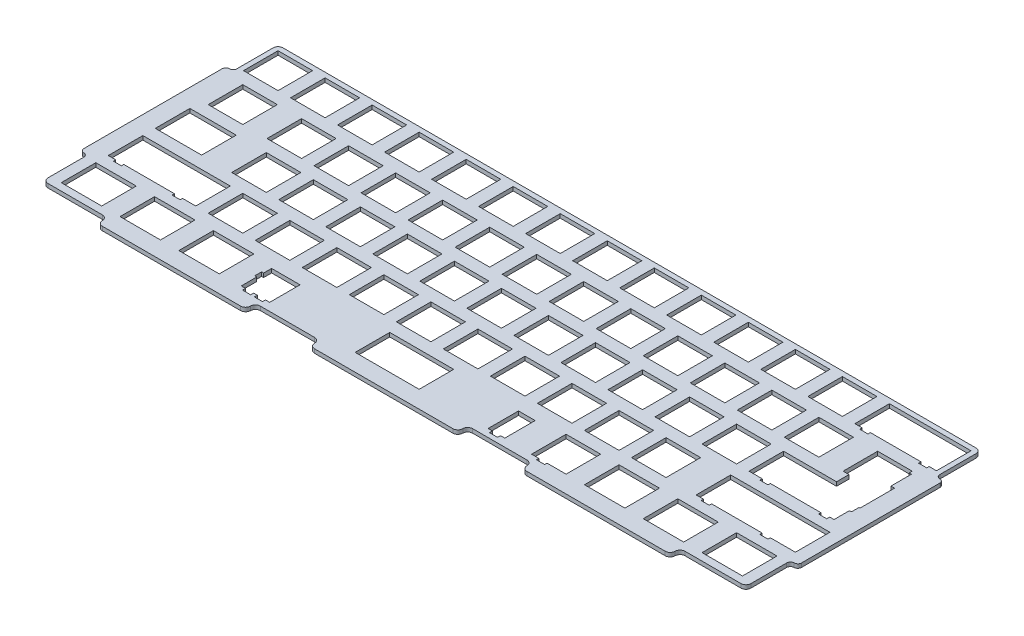
from build123d import *

# Parameters (mm, degrees)
SKETCH1_W           = 16.381
SKETCH1_H           = 13.99946
SKETCH1_W_2         = 16.38
SKETCH1_W_3         = 16.3805
SKETCH1_W_4         = 16.382
SKETCH1_W_5         = 16.38079
SKETCH1_W_6         = 14
SKETCH1_H_2         = 13.9994
SKETCH1_W_7         = 13.9993
SKETCH1_H_3         = 13.9993
SKETCH1_W_8         = 13.9998
SKETCH1_W_9         = 18.76199
SKETCH1_W_10        = 13.999
SKETCH1_W_11        = 13.99954
SKETCH1_W_12        = 14.001
SKETCH1_W_13        = 14.0007
SKETCH1_W_14        = 13.99955
BOSS_EXTRUDE2_DEPTH = 1.6


with BuildPart() as part:
    # Sketch1 → Boss-Extrude2 (new body)
    with BuildSketch(Plane(origin=(0, 0, 0), x_dir=(1, 0, 0), z_dir=(0, 1, 0))):
        with BuildLine():
            Line((-113.173608787, -49.920818918), (-57.173608787, -49.920818918))
            ThreePointArc((-57.173608787, -49.920818918), (-55.759395225, -49.33503248), (-55.173608787, -47.920818918))
            ThreePointArc((-55.173608787, -47.920818918), (-54.58782235, -46.506605356), (-53.173608787, -45.920818918))
            Line((-53.173608787, -45.920818918), (-31.173608787, -45.920818918))
            ThreePointArc((-31.173608787, -45.920818918), (-29.759395225, -46.506605356), (-29.173608787, -47.920818918))
            ThreePointArc((-29.173608787, -47.920818918), (-28.58782235, -49.33503248), (-27.173608787, -49.920818918))
            Line((-27.173608787, -49.920818918), (28.826391213, -49.920818918))
            ThreePointArc((28.826391213, -49.920818918), (30.240604775, -49.33503248), (30.826391213, -47.920818918))
            ThreePointArc((30.826391213, -47.920818918), (31.41217765, -46.506605356), (32.826391213, -45.920818918))
            Line((32.826391213, -45.920818918), (54.826391213, -45.920818918))
            ThreePointArc((54.826391213, -45.920818918), (56.240604775, -46.506605356), (56.826391213, -47.920818918))
            ThreePointArc((56.826391213, -47.920818918), (57.41217765, -49.33503248), (58.826391213, -49.920818918))
            Line((58.826391213, -49.920818918), (114.826391213, -49.920818918))
            ThreePointArc((114.826391213, -49.920818918), (116.240604775, -49.33503248), (116.826391213, -47.920818918))
            ThreePointArc((116.826391213, -47.920818918), (117.41217765, -46.506605356), (118.826391213, -45.920818918))
            Line((118.826391213, -45.920818918), (141.525741213, -45.920818918))
            ThreePointArc((141.525741213, -45.920818918), (142.939954775, -45.33503248), (143.525741213, -43.920818918))
            Line((143.525741213, -43.920818918), (143.525741213, -29.420818918))
            ThreePointArc((143.525741213, -29.420818918), (143.965081041, -28.360158746), (145.025741213, -27.920818918))
            ThreePointArc((145.025741213, -27.920818918), (146.086401385, -27.48147909), (146.525741213, -26.420818918))
            Line((146.525741213, -26.420818918), (146.525741213, 29.579181082))
            ThreePointArc((146.525741213, 29.579181082), (146.086401385, 30.639841254), (145.025741213, 31.079181082))
            ThreePointArc((145.025741213, 31.079181082), (143.965081041, 31.51852091), (143.525741213, 32.579181082))
            Line((143.525741213, 32.579181082), (143.525741213, 47.248781082))
            ThreePointArc((143.525741213, 47.248781082), (142.939954775, 48.662994644), (141.525741213, 49.248781082))
            Line((141.525741213, 49.248781082), (-139.173608787, 49.248781082))
            ThreePointArc((-139.173608787, 49.248781082), (-140.58782235, 48.662994644), (-141.173608787, 47.248781082))
            Line((-141.173608787, 47.248781082), (-141.173608787, 32.579181082))
            ThreePointArc((-141.173608787, 32.579181082), (-141.612948615, 31.51852091), (-142.673608787, 31.079181082))
            ThreePointArc((-142.673608787, 31.079181082), (-143.734268959, 30.639841254), (-144.173608787, 29.579181082))
            Line((-144.173608787, 29.579181082), (-144.173608787, -26.420818918))
            ThreePointArc((-144.173608787, -26.420818918), (-143.734268959, -27.48147909), (-142.673608787, -27.920818918))
            ThreePointArc((-142.673608787, -27.920818918), (-141.612948615, -28.360158746), (-141.173608787, -29.420818918))
            Line((-141.173608787, -29.420818918), (-141.173608787, -43.920818918))
            ThreePointArc((-141.173608787, -43.920818918), (-140.58782235, -45.33503248), (-139.173608787, -45.920818918))
            Line((-139.173608787, -45.920818918), (-117.173608787, -45.920818918))
            ThreePointArc((-117.173608787, -45.920818918), (-115.759395225, -46.506605356), (-115.173608787, -47.920818918))
            ThreePointArc((-115.173608787, -47.920818918), (-114.58782235, -49.33503248), (-113.173608787, -49.920818918))
        make_face()
        Polygon((-17.731258787, -28.951218918), (-17.731258787, -33.651718918), (-17.731258787, -42.950678918), (8.175741213, -42.950678918), (8.175741213, -38.251588918), (8.175741213, -33.651718918), (8.175741213, -28.951218918), align=None, mode=Mode.SUBTRACT)
        Polygon((-52.598358787, -33.651718918), (-52.598358787, -30.421518918), (-64.106258787, -30.421518918), (-64.106258787, -33.651718918), (-64.930358787, -33.651718918), (-64.930358787, -36.450478918), (-64.106258787, -36.450478918), (-64.106258787, -42.720548918), (-62.381258787, -42.720548918), (-62.381258787, -43.920818918), (-59.080658787, -43.920818918), (-59.080658787, -42.720548918), (-57.624058787, -42.720548918), (-57.624058787, -43.920818918), (-54.323758787, -43.920818918), (-54.323758787, -42.720548918), (-52.598358787, -42.720548918), (-52.598358787, -38.251588918), align=None, mode=Mode.SUBTRACT)
        Polygon((35.893741213, -33.651718918), (35.893741213, -42.720548918), (37.618741213, -42.720548918), (37.618741213, -43.920818918), (40.919741213, -43.920818918), (40.919741213, -42.720548918), (42.644741213, -42.720548918), (42.644741213, -38.251588918), (42.644741213, -33.651718918), (42.644741213, -30.421518918), (35.893741213, -30.421518918), align=None, mode=Mode.SUBTRACT)
        Polygon((53.707741213, -38.251588918), (53.707741213, -42.950678918), (56.675741213, -42.950678918), (56.675741213, -43.920818918), (59.975741213, -43.920818918), (59.975741213, -42.950678918), (67.706741213, -42.950678918), (67.706741213, -28.951218918), (53.707741213, -28.951218918), (53.707741213, -33.651718918), align=None, mode=Mode.SUBTRACT)
        with Locations((130.954241213, -35.950948918)):
            Rectangle(SKETCH1_W, SKETCH1_H, mode=Mode.SUBTRACT)
        with Locations((107.141741213, -35.950948918)):
            Rectangle(SKETCH1_W_2, SKETCH1_H, mode=Mode.SUBTRACT)
        with Locations((83.329241213, -35.950948918)):
            Rectangle(SKETCH1_W, SKETCH1_H, mode=Mode.SUBTRACT)
        with Locations((-80.977008787, -35.950948918)):
            Rectangle(SKETCH1_W_3, SKETCH1_H, mode=Mode.SUBTRACT)
        with Locations((-104.790258787, -35.950948918)):
            Rectangle(SKETCH1_W_4, SKETCH1_H, mode=Mode.SUBTRACT)
        with Locations((-128.601953787, -35.950948918)):
            Rectangle(SKETCH1_W_5, SKETCH1_H, mode=Mode.SUBTRACT)
        Polygon((101.332741213, -9.901318918), (101.332741213, -23.900718918), (104.307741213, -23.900718918), (104.307741213, -24.870818918), (107.606741213, -24.870818918), (107.606741213, -23.900718918), (124.856741213, -23.900718918), (127.526741213, -23.900718918), (128.106741213, -23.900718918), (128.106741213, -24.870818918), (131.406741213, -24.870818918), (131.406741213, -23.900718918), (141.525741213, -23.900718918), (141.525741213, -9.901318918), (127.526741213, -9.901318918), (124.856741213, -9.901318918), align=None, mode=Mode.SUBTRACT)
        Polygon((-136.792348787, -9.901318918), (-136.792348787, -23.900718918), (-133.817168787, -23.900718918), (-133.817168787, -24.870818918), (-130.518158787, -24.870818918), (-130.518158787, -23.900718918), (-110.018458787, -23.900718918), (-110.018458787, -24.870818918), (-106.718058787, -24.870818918), (-106.718058787, -23.900718918), (-101.361758787, -23.900718918), (-101.361758787, -9.901318918), align=None, mode=Mode.SUBTRACT)
        with Locations((82.138741213, -16.901018918)):
            Rectangle(SKETCH1_W_6, SKETCH1_H_2, mode=Mode.SUBTRACT)
        with Locations((63.088741213, -16.901018918)):
            Rectangle(SKETCH1_W_6, SKETCH1_H_2, mode=Mode.SUBTRACT)
        with Locations((44.038741213, -16.901018918)):
            Rectangle(SKETCH1_W_6, SKETCH1_H_2, mode=Mode.SUBTRACT)
        with Locations((24.988741213, -16.901018918)):
            Rectangle(SKETCH1_W_6, SKETCH1_H_2, mode=Mode.SUBTRACT)
        with Locations((5.938741213, -16.901018918)):
            Rectangle(SKETCH1_W_6, SKETCH1_H_2, mode=Mode.SUBTRACT)
        with Locations((-13.111258787, -16.901018918)):
            Rectangle(SKETCH1_W_6, SKETCH1_H_2, mode=Mode.SUBTRACT)
        with Locations((-32.161258787, -16.901018918)):
            Rectangle(SKETCH1_W_6, SKETCH1_H_2, mode=Mode.SUBTRACT)
        with Locations((-51.211408787, -16.901018918)):
            Rectangle(SKETCH1_W_7, SKETCH1_H_2, mode=Mode.SUBTRACT)
        with Locations((-70.261408787, -16.901018918)):
            Rectangle(SKETCH1_W_7, SKETCH1_H_2, mode=Mode.SUBTRACT)
        with Locations((-89.311408787, -16.901018918)):
            Rectangle(SKETCH1_W_7, SKETCH1_H_2, mode=Mode.SUBTRACT)
        Polygon((122.763741213, 28.198781082), (122.763741213, 14.199481082), (125.143741213, 14.199481082), (125.143741213, 9.148781082), (103.713741213, 9.148781082), (103.713741213, -4.850518918), (109.068741213, -4.850518918), (109.068741213, -5.820718918), (112.367741213, -5.820718918), (112.367741213, -4.850518918), (129.619741213, -4.850518918), (132.868741213, -4.850518918), (132.868741213, -5.820718918), (136.169741213, -5.820718918), (136.169741213, -4.620518918), (137.894741213, -4.620518918), (137.894741213, 1.649381082), (138.718741213, 1.649381082), (138.718741213, 4.448281082), (138.718741213, 4.674481082), (139.144741213, 4.674481082), (139.144741213, 18.673781082), (137.673741213, 18.673781082), (137.673741213, 20.199181082), (137.673741213, 26.948881082), (136.763741213, 26.948881082), (136.763741213, 28.198781082), align=None, mode=Mode.SUBTRACT)
        with Locations((91.663741213, 2.149131082)):
            Rectangle(SKETCH1_W_6, SKETCH1_H_3, mode=Mode.SUBTRACT)
        with Locations((72.613741213, 2.149131082)):
            Rectangle(SKETCH1_W_6, SKETCH1_H_3, mode=Mode.SUBTRACT)
        with Locations((53.563741213, 2.149131082)):
            Rectangle(SKETCH1_W_6, SKETCH1_H_3, mode=Mode.SUBTRACT)
        with Locations((34.513741213, 2.149131082)):
            Rectangle(SKETCH1_W_6, SKETCH1_H_3, mode=Mode.SUBTRACT)
        with Locations((15.463741213, 2.149131082)):
            Rectangle(SKETCH1_W_6, SKETCH1_H_3, mode=Mode.SUBTRACT)
        with Locations((-3.586258787, 2.149131082)):
            Rectangle(SKETCH1_W_6, SKETCH1_H_3, mode=Mode.SUBTRACT)
        with Locations((-22.636258787, 2.149131082)):
            Rectangle(SKETCH1_W_6, SKETCH1_H_3, mode=Mode.SUBTRACT)
        with Locations((-41.686158787, 2.149131082)):
            Rectangle(SKETCH1_W_8, SKETCH1_H_3, mode=Mode.SUBTRACT)
        with Locations((-60.736408787, 2.149131082)):
            Rectangle(SKETCH1_W_7, SKETCH1_H_3, mode=Mode.SUBTRACT)
        with Locations((-79.786408787, 2.149131082)):
            Rectangle(SKETCH1_W_7, SKETCH1_H_3, mode=Mode.SUBTRACT)
        with Locations((-98.836408787, 2.149131082)):
            Rectangle(SKETCH1_W_7, SKETCH1_H_3, mode=Mode.SUBTRACT)
        with Locations((-127.411353787, 2.149131082)):
            Rectangle(SKETCH1_W_9, SKETCH1_H_3, mode=Mode.SUBTRACT)
        with Locations((105.951241213, 21.199131082)):
            Rectangle(SKETCH1_W_10, SKETCH1_H_3, mode=Mode.SUBTRACT)
        with Locations((86.901241213, 21.199131082)):
            Rectangle(SKETCH1_W_10, SKETCH1_H_3, mode=Mode.SUBTRACT)
        with Locations((67.851241213, 21.199131082)):
            Rectangle(SKETCH1_W_10, SKETCH1_H_3, mode=Mode.SUBTRACT)
        with Locations((48.801241213, 21.199131082)):
            Rectangle(SKETCH1_W_10, SKETCH1_H_3, mode=Mode.SUBTRACT)
        with Locations((29.751241213, 21.199131082)):
            Rectangle(SKETCH1_W_10, SKETCH1_H_3, mode=Mode.SUBTRACT)
        with Locations((10.701241213, 21.199131082)):
            Rectangle(SKETCH1_W_10, SKETCH1_H_3, mode=Mode.SUBTRACT)
        with Locations((-8.348758787, 21.199131082)):
            Rectangle(SKETCH1_W_10, SKETCH1_H_3, mode=Mode.SUBTRACT)
        with Locations((-27.398758787, 21.199131082)):
            Rectangle(SKETCH1_W_10, SKETCH1_H_3, mode=Mode.SUBTRACT)
        with Locations((-46.448908787, 21.199131082)):
            Rectangle(SKETCH1_W_7, SKETCH1_H_3, mode=Mode.SUBTRACT)
        with Locations((-65.498908787, 21.199131082)):
            Rectangle(SKETCH1_W_7, SKETCH1_H_3, mode=Mode.SUBTRACT)
        with Locations((-84.548908787, 21.199131082)):
            Rectangle(SKETCH1_W_7, SKETCH1_H_3, mode=Mode.SUBTRACT)
        with Locations((-103.598908787, 21.199131082)):
            Rectangle(SKETCH1_W_7, SKETCH1_H_3, mode=Mode.SUBTRACT)
        with Locations((-127.411328787, 21.199131082)):
            Rectangle(SKETCH1_W_11, SKETCH1_H_3, mode=Mode.SUBTRACT)
        Polygon((108.476741213, 47.248781082), (108.476741213, 33.249481082), (111.449741213, 33.249481082), (111.449741213, 32.279281082), (114.750741213, 32.279281082), (114.750741213, 33.249481082), (135.251741213, 33.249481082), (135.251741213, 32.279281082), (138.550741213, 32.279281082), (138.550741213, 33.249481082), (141.525741213, 33.249481082), (141.525741213, 47.248781082), align=None, mode=Mode.SUBTRACT)
        with Locations((96.426241213, 40.249131082)):
            Rectangle(SKETCH1_W_10, SKETCH1_H_3, mode=Mode.SUBTRACT)
        with Locations((77.376241213, 40.249131082)):
            Rectangle(SKETCH1_W_10, SKETCH1_H_3, mode=Mode.SUBTRACT)
        with Locations((58.326241213, 40.249131082)):
            Rectangle(SKETCH1_W_10, SKETCH1_H_3, mode=Mode.SUBTRACT)
        with Locations((39.276241213, 40.249131082)):
            Rectangle(SKETCH1_W_10, SKETCH1_H_3, mode=Mode.SUBTRACT)
        with Locations((20.226241213, 40.249131082)):
            Rectangle(SKETCH1_W_10, SKETCH1_H_3, mode=Mode.SUBTRACT)
        with Locations((1.176241213, 40.249131082)):
            Rectangle(SKETCH1_W_10, SKETCH1_H_3, mode=Mode.SUBTRACT)
        with Locations((-17.874758787, 40.249131082)):
            Rectangle(SKETCH1_W_12, SKETCH1_H_3, mode=Mode.SUBTRACT)
        with Locations((-36.924608787, 40.249131082)):
            Rectangle(SKETCH1_W_13, SKETCH1_H_3, mode=Mode.SUBTRACT)
        with Locations((-55.973908787, 40.249131082)):
            Rectangle(SKETCH1_W_7, SKETCH1_H_3, mode=Mode.SUBTRACT)
        with Locations((-75.023908787, 40.249131082)):
            Rectangle(SKETCH1_W_7, SKETCH1_H_3, mode=Mode.SUBTRACT)
        with Locations((-94.073908787, 40.249131082)):
            Rectangle(SKETCH1_W_7, SKETCH1_H_3, mode=Mode.SUBTRACT)
        with Locations((-113.123908787, 40.249131082)):
            Rectangle(SKETCH1_W_7, SKETCH1_H_3, mode=Mode.SUBTRACT)
        with Locations((-132.173833787, 40.249131082)):
            Rectangle(SKETCH1_W_14, SKETCH1_H_3, mode=Mode.SUBTRACT)
    extrude(amount=BOSS_EXTRUDE2_DEPTH)


solid = part.part
